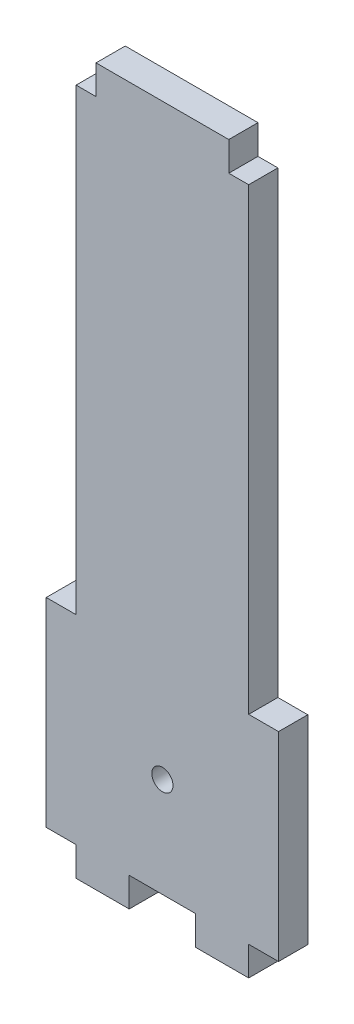
from build123d import *

# Parameters (mm, degrees)
EXTRUDE_1_DEPTH     = 4.4
SKETCH_2_R          = 1.6
CUT_EXTRUDE_1_DEPTH = 10
EXTRUDE_2_DEPTH     = 4.4


with BuildPart() as part:
    # 草图1 → 凸台-拉伸1 (new body)
    with BuildSketch(Plane.XY):
        Polygon((5, 19.4), (5, 15), (-5, 15), (-5, 19.4), (-13, 19.4), (-13, 15), (-17.5, 15), (-17.5, -15), (-13, -15), (-13, -19.4), (-5, -19.4), (-5, -15), (5, -15), (5, -19.4), (13, -19.4), (13, -15), (17.5, -15), (17.5, 15), (13, 15), (13, 19.4), align=None)
    extrude(amount=EXTRUDE_1_DEPTH)

    # 草图2 → 切除-拉伸1 (cut)
    with BuildSketch(Plane.XY.offset(4.4)):
        Circle(SKETCH_2_R)
    extrude(amount=-CUT_EXTRUDE_1_DEPTH, mode=Mode.SUBTRACT)

    # 草图3 → 凸台-拉伸2 (add)
    with BuildSketch(Plane.XY.offset(4.4)):
        Polygon((10, 88.5), (10, 84.1), (13, 84.1), (13, 15), (-13, 15), (-13, 84.1), (-10, 84.1), (-10, 88.5), align=None)
    extrude(amount=-EXTRUDE_2_DEPTH)


solid = part.part
